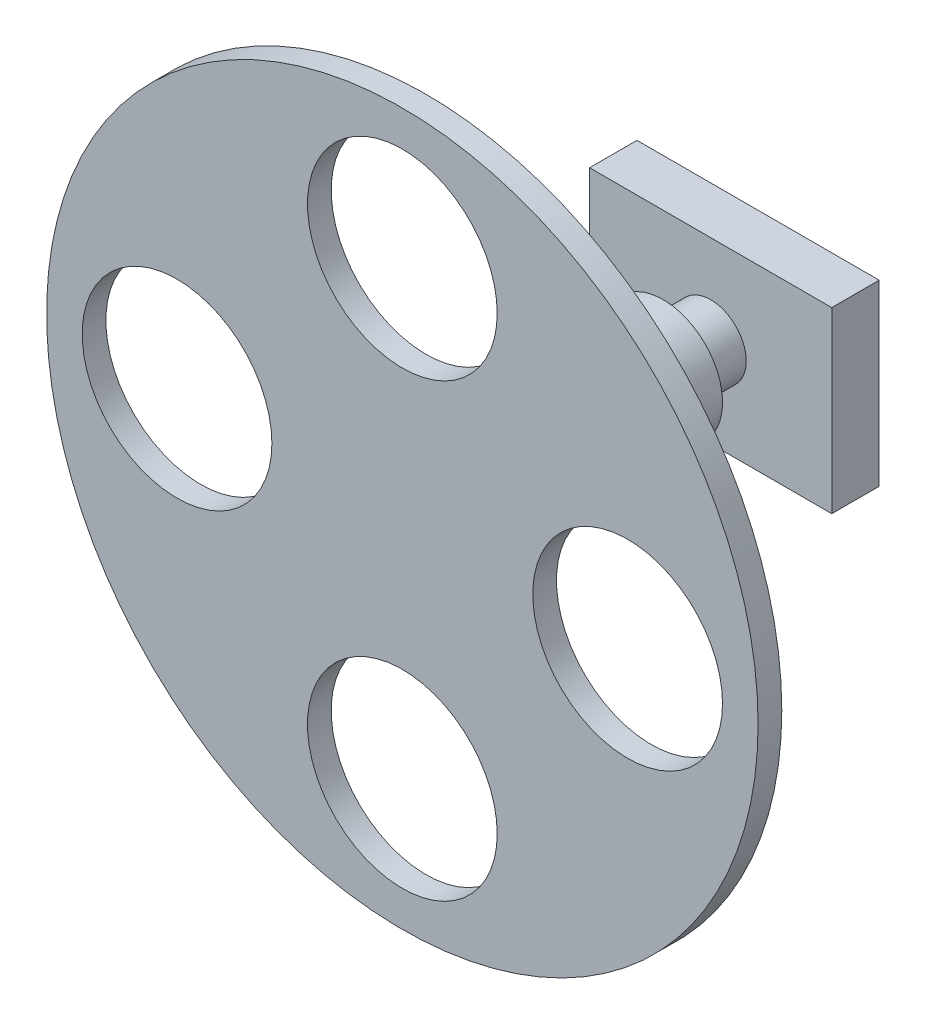
from build123d import *

# Parameters (mm, degrees)
SKETCH1_R           = 150
SKETCH1_R_2         = 40
BOSS_EXTRUDE1_DEPTH = 10
SKETCH2_R           = 25
BOSS_EXTRUDE2_DEPTH = 100
SKETCH3_R           = 15
BOSS_EXTRUDE3_DEPTH = 20
SKETCH4_W           = 102.125411964
SKETCH4_H           = 75.272699472
BOSS_EXTRUDE4_DEPTH = 20


with BuildPart() as part:
    # Sketch1 → Boss-Extrude1 (new body)
    with BuildSketch(Plane.XY):
        Circle(SKETCH1_R)
        with Locations((0, 95)):
            Circle(SKETCH1_R_2, mode=Mode.SUBTRACT)
        with Locations((95, 0)):
            Circle(SKETCH1_R_2, mode=Mode.SUBTRACT)
        with Locations((0, -95)):
            Circle(SKETCH1_R_2, mode=Mode.SUBTRACT)
        with Locations((-95, 0)):
            Circle(SKETCH1_R_2, mode=Mode.SUBTRACT)
    extrude(amount=BOSS_EXTRUDE1_DEPTH)

    # Sketch2 → Boss-Extrude2 (add)
    with BuildSketch(Plane(origin=(0, 0, 0), x_dir=(-1, 0, 0), z_dir=(0, 0, -1))):
        Circle(SKETCH2_R)
    extrude(amount=BOSS_EXTRUDE2_DEPTH)

    # Sketch3 → Boss-Extrude3 (add)
    with BuildSketch(Plane(origin=(0, 0, -100), x_dir=(-1, 0, 0), z_dir=(0, 0, -1))):
        Circle(SKETCH3_R)
    extrude(amount=BOSS_EXTRUDE3_DEPTH)

    # Sketch4 → Boss-Extrude4 (add)
    with BuildSketch(Plane(origin=(0, 0, -120), x_dir=(-1, 0, 0), z_dir=(0, 0, -1))):
        Rectangle(SKETCH4_W, SKETCH4_H)
    extrude(amount=BOSS_EXTRUDE4_DEPTH)


solid = part.part
